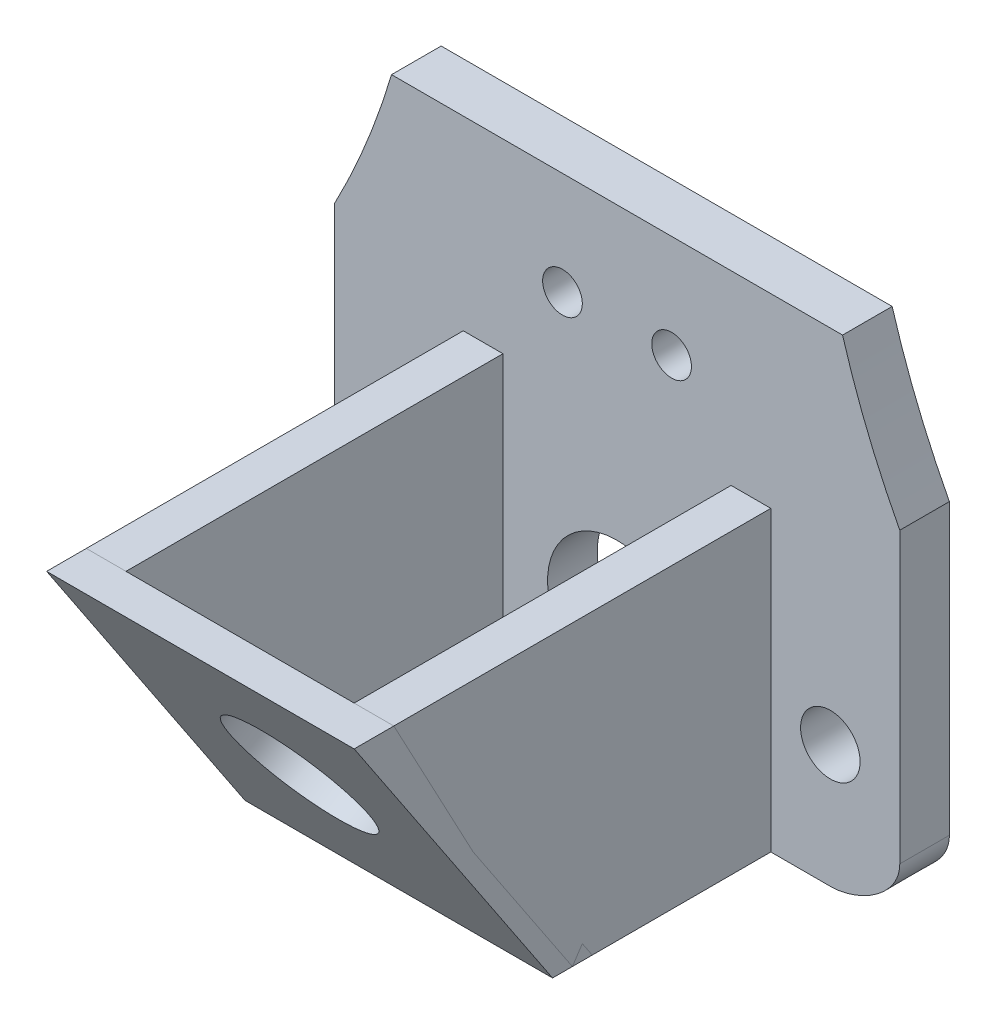
from build123d import *

# Parameters (mm, degrees)
MODEL_R              = 1.5
EXTRUDE_1_DEPTH      = 2.5
SKETCH_2_W           = 21
SKETCH_2_H           = 22
SKETCH_2_W_2         = 19
SKETCH_2_H_2         = 19.020798255
EXTRUDE_2_DEPTH      = 7
SKETCH_3_W           = 1.5
SKETCH_3_H           = 5
EXTRUDE_3_DEPTH      = 7
CUT_EXTRUDE_2_DEPTH  = 7
EXTRUDE_6_DEPTH      = 7
CUT_EXTRUDE_4_DEPTH  = 7
SKETCH_13_W          = 2
SKETCH_13_H          = 2
CUT_EXTRUDE_5_DEPTH  = 7
EXTRUDE_7_DEPTH      = 20
CUT_EXTRUDE_6_DEPTH  = 20
SKETCH_20_W          = 15.5
SKETCH_20_H          = 18.027756377
EXTRUDE_9_DEPTH      = 1
SKETCH_21_R          = 3.5
CUT_EXTRUDE_7_DEPTH  = 2
SKETCH_23_R          = 3.5
CUT_EXTRUDE_8_DEPTH  = 4
SKETCH_25_W          = 3
SKETCH_25_H          = 13
EXTRUDE_10_DEPTH     = 15
SKETCH_26_R          = 2.5
CUT_EXTRUDE_9_DEPTH  = 18
CUT_EXTRUDE_10_DEPTH = 16
SKETCH_28_W          = 2.683621922
SKETCH_28_H          = 2
CUT_EXTRUDE_12_DEPTH = 2
SKETCH_30_R          = 1
CUT_EXTRUDE_13_DEPTH = 10
SKETCH_31_R          = 39
CUT_EXTRUDE_14_DEPTH = 10
SKETCH_33_R          = 1
CUT_EXTRUDE_15_DEPTH = 2.5
EXTRUDE_13_DEPTH     = 2.5
CUT_EXTRUDE_16_DEPTH = 40.5


with BuildPart() as part:
    # Model → 凸台-拉伸1 (new body)
    with BuildSketch(Plane.XY):
        with BuildLine():
            Line((35.686511473, 106.179045823), (14.686511473, 106.179045823))
            Line((14.686511473, 106.179045823), (14.686511473, 84.179045823))
            add(Edge.make_bspline(
                [(14.686511473, 84.179045823), (12.217125861, 84.179045823), (10.936511473, 82.388902867), (10.936511473, 80.679045823)],
                knots=[0, 0, 0, 0, 5.129571132, 5.129571132, 5.129571132, 5.129571132], degree=3))
            Line((10.936511473, 80.679045823), (10.936511473, 18.679045823))
            add(Edge.make_bspline(
                [(10.936511473, 18.679045823), (10.936511473, 17.199254946), (12.956720596, 15.948106541), (14.436511473, 15.948106541)],
                knots=[0, 0, 0, 0, 4.439372631, 4.439372631, 4.439372631, 4.439372631], degree=3))
            Line((14.436511473, 15.948106541), (35.936511473, 15.948106541))
            add(Edge.make_bspline(
                [(39.436511473, 18.679045823), (39.436511473, 17.199254946), (37.41630235, 15.948106541), (35.936511473, 15.948106541)],
                knots=[0, 0, 0, 0, 4.439372631, 4.439372631, 4.439372631, 4.439372631], degree=3))
            Line((39.436511473, 18.679045823), (39.436511473, 80.679045823))
            add(Edge.make_bspline(
                [(35.686511473, 84.179045823), (38.155897084, 84.179045823), (39.436511473, 82.388902867), (39.436511473, 80.679045823)],
                knots=[0, 0, 0, 0, 5.129571132, 5.129571132, 5.129571132, 5.129571132], degree=3))
            Line((35.686511473, 84.179045823), (35.686511473, 106.179045823))
        make_face()
        with Locations((14.436511473, 22.132696196)):
            Circle(MODEL_R, mode=Mode.SUBTRACT)
        with Locations((35.936511473, 22.132696196)):
            Circle(MODEL_R, mode=Mode.SUBTRACT)
        with Locations((14.436511473, 80.679045823)):
            Circle(MODEL_R, mode=Mode.SUBTRACT)
        with Locations((35.936511473, 80.679045823)):
            Circle(MODEL_R, mode=Mode.SUBTRACT)
    extrude(amount=EXTRUDE_1_DEPTH)

    # 草图2 → 凸台-拉伸2 (add)
    with BuildSketch(Plane.XY.offset(2.5)):
        with Locations((25.186511473, 95.179045823)):
            Rectangle(SKETCH_2_W, SKETCH_2_H)
        with Locations((25.18651147, 95.501249058)):
            Rectangle(SKETCH_2_W_2, SKETCH_2_H_2, mode=Mode.SUBTRACT)
    extrude(amount=EXTRUDE_2_DEPTH)

    # 草图3 → 凸台-拉伸3 (add)
    with BuildSketch(Plane.XY.offset(2.5)):
        with Locations((20.120133395, 81.679045823)):
            Rectangle(SKETCH_3_W, SKETCH_3_H)
    extrude(amount=EXTRUDE_3_DEPTH)

    # 草图4 → 切除-拉伸2 (cut)
    with BuildSketch(Plane.ZY.offset(-19.370133395)):
        Polygon((9.5, 84.179045823), (2.5, 79.179045823), (9.5, 79.179045823), align=None)
    extrude(amount=-CUT_EXTRUDE_2_DEPTH, mode=Mode.SUBTRACT)

    # Sketch 3D_1 → 凸台-拉伸6 (add)
    with BuildSketch(Plane(origin=(31.006511473, 84.179045823, 2.5), x_dir=(-0.28734788556634544, -0.9578262852211514, 0), z_dir=(0, 0, -1))):
        Polygon((0, 0), (0.431021828, 1.436739428), (5.220153254, 0), (4.789131426, -1.436739428), align=None)
    extrude(amount=-EXTRUDE_6_DEPTH)

    # 草图12 → 切除-拉伸4 (cut)
    with BuildSketch(Plane.ZY.offset(-29.506511473)):
        Polygon((9.5, 84.179045823), (9.5, 79.179045823), (2.5, 79.179045823), align=None)
    extrude(amount=-CUT_EXTRUDE_4_DEPTH, mode=Mode.SUBTRACT)

    # 草图13 → 切除-拉伸5 (cut)
    with BuildSketch(Plane.XZ.offset(-84.179045823)):
        with Locations((25.186511473, 3.5)):
            Rectangle(SKETCH_13_W, SKETCH_13_H)
    extrude(amount=-CUT_EXTRUDE_5_DEPTH, mode=Mode.SUBTRACT)

    # 草图14 → 凸台-拉伸7 (add)
    with BuildSketch(Plane.XY.offset(2.5)):
        Polygon((19.436511473, 30.948106541), (19.436511473, 17.948106541), (30.936511473, 17.948106541), (30.936511473, 30.948106541), (32.936511473, 30.948106541), (32.936511473, 15.948106541), (17.436511473, 15.948106541), (17.436511473, 30.948106541), align=None)
    extrude(amount=EXTRUDE_7_DEPTH)

    # 草图15 → 切除-拉伸6 (cut)
    with BuildSketch(Plane.ZY.offset(-17.436511473)):
        Polygon((22.5, 30.948106541), (22.5, 15.948106541), (12.5, 15.948106541), align=None)
    extrude(amount=-CUT_EXTRUDE_6_DEPTH, mode=Mode.SUBTRACT)

    # 草图23 → 切除-拉伸8 (cut)
    with BuildSketch(Plane.XY.offset(2.5)):
        with Locations((25.186511473, 22.179045823)):
            Circle(SKETCH_23_R)
    extrude(amount=-CUT_EXTRUDE_8_DEPTH, mode=Mode.SUBTRACT)

    # 草图25 → 凸台-拉伸10 (add)
    with BuildSketch(Plane.XY.offset(2.5)):
        Polygon((25.186511473, 73.429045823), (26.214511031, 73.429045823), (26.214511031, 60.429045823), (24.186511473, 60.429045823), (24.186511473, 73.429045823), align=None)
        with Locations((31.686511473, 66.929045823)):
            Rectangle(SKETCH_25_W, SKETCH_25_H)
        with Locations((18.686511473, 66.929045823)):
            Rectangle(SKETCH_25_W, SKETCH_25_H)
    extrude(amount=EXTRUDE_10_DEPTH)

    # 草图26 → 切除-拉伸9 (cut)
    with BuildSketch(Plane.ZY.offset(-17.186511473)):
        with Locations(Location((11, 66.929045823, 0), (0, 0, 270))):
            Circle(SKETCH_26_R)
    extrude(amount=-CUT_EXTRUDE_9_DEPTH, mode=Mode.SUBTRACT)

    # 草图27 → 切除-拉伸10 (cut)
    with BuildSketch(Plane.ZY.offset(-17.186511473)):
        with BuildLine():
            Line((11, 73.429045823), (11, 75.536501325))
            Line((11, 75.536501325), (21.747083052, 75.536501325))
            Line((21.747083052, 75.536501325), (21.747083052, 59.045875477))
            Line((21.747083052, 59.045875477), (11, 59.431370627))
            Line((11, 59.431370627), (11, 60.429045823))
            ThreePointArc((11, 60.429045823), (17.5, 66.929045823), (11, 73.429045823))
        make_face()
    extrude(amount=-CUT_EXTRUDE_10_DEPTH, mode=Mode.SUBTRACT)

    # 草图28 → 切除-拉伸12 (cut)
    with BuildSketch(Plane.XZ.offset(-84.179045823)):
        with Locations((18.028322434, 3.5)):
            Rectangle(SKETCH_28_W, SKETCH_28_H)
        Polygon((31.001439257, 2.495787232), (33.685060474, 2.493843259), (33.686509243, 4.493842734), (31.002888025, 4.495786707), align=None)
    extrude(amount=-CUT_EXTRUDE_12_DEPTH, mode=Mode.SUBTRACT)

    # 草图30 → 切除-拉伸13 (cut)
    with BuildSketch(Plane.XY.offset(2.5)):
        with Locations((28.188322434, 55.179045823)):
            Circle(SKETCH_30_R)
        with Locations((22.188322434, 54.179045823)):
            Circle(SKETCH_30_R)
    extrude(amount=-CUT_EXTRUDE_13_DEPTH, mode=Mode.SUBTRACT)

    # 草图31 → 切除-拉伸14 (cut)
    with BuildSketch(Plane.XY.offset(2.5)):
        with Locations((-23.563488527, 51.429045823)):
            Circle(SKETCH_31_R)
        with Locations((73.936511473, 51.429045823)):
            Circle(SKETCH_31_R)
    extrude(amount=-CUT_EXTRUDE_14_DEPTH, mode=Mode.SUBTRACT)

    # 草图33 → 切除-拉伸15 (cut)
    with BuildSketch(Plane.XY.offset(2.5)):
        with Locations((22.436511473, 35.132696196)):
            Circle(SKETCH_33_R)
        with Locations((27.936511473, 35.132696196)):
            Circle(SKETCH_33_R)
    extrude(amount=-CUT_EXTRUDE_15_DEPTH, mode=Mode.SUBTRACT)

    # 草图32 → 凸台-拉伸13 (add)
    with BuildSketch(Plane.XY.offset(2.5)):
        with BuildLine():
            Line((17.214511031, 60.429045823), (15.297431543, 47.822900451))
            add(Edge.make_bspline(
                [(17.214511031, 60.429045823), (16.402774166, 57.261824787), (15.879635601, 55.030502336), (6.038156358, 53.300869438), (2.601041084, 54.562530921), (2.767654696, 53.014775012), (5.153806778, 51.137514182), (9.250259364, 48.687019635), (9.753110129, 48.526716356), (15.297431543, 47.822900451)],
                knots=[0, 0, 0, 0, 0.228683763, 0.270207351, 0.399121597, 0.431668139, 0.563126225, 0.621602637, 1, 1, 1, 1], degree=3))
        make_face()
        with BuildLine():
            Line((33.186511473, 60.429045823), (35.10359096, 47.822900451))
            add(Edge.make_bspline(
                [(33.186511473, 60.429045823), (33.998248337, 57.261824787), (34.521386902, 55.030502336), (44.362866145, 53.300869438), (47.79998142, 54.562530921), (47.633367808, 53.014775012), (45.247215725, 51.137514182), (41.150763139, 48.687019635), (40.647912374, 48.526716356), (35.10359096, 47.822900451)],
                knots=[0, 0, 0, 0, 0.228683763, 0.270207351, 0.399121597, 0.431668139, 0.563126225, 0.621602637, 1, 1, 1, 1], degree=3))
        make_face()
    extrude(amount=-EXTRUDE_13_DEPTH)

    # 草图34 → 切除-拉伸16 (cut, symmetric)
    with BuildSketch(Plane.XY.offset(2.5)):
        Polygon((13.821184983, 40.321112329), (36.55234053, 40.319421035), (46.082104671, 32.132653457), (58.914368783, 113.092574309), (0, 109.126238129), (-4.080382313, 42.2818078), align=None)
    extrude(amount=CUT_EXTRUDE_16_DEPTH, both=True, mode=Mode.SUBTRACT)


with BuildPart() as body_2:
    # 草图20 → 凸台-拉伸9 (new, symmetric, along a direction that is not the sketch's normal)
    with BuildSketch(Plane(origin=(0, -0.862121064, 1.293181596), x_dir=(1, 0, 0), z_dir=(0, -0.5547001962252294, 0.8320502943378436))):
        with Locations((25.186511473, 29.217257383)):
            Rectangle(SKETCH_20_W, SKETCH_20_H)
    extrude(amount=EXTRUDE_9_DEPTH, dir=(0, 0, 1), both=True)

    # 草图21 → 切除-拉伸7 (cut)
    with BuildSketch(Plane(origin=(0, -1.323659526, 1.985489289), x_dir=(1, 0, 0), z_dir=(0, -0.5547001962252295, 0.8320502943378434))):
        with Locations(Location((25.186511473, 29.771957579, 0), (0, 0, 270))):
            Circle(SKETCH_21_R)
    extrude(amount=-CUT_EXTRUDE_7_DEPTH, mode=Mode.SUBTRACT)


solid = Compound([part.part, body_2.part])
